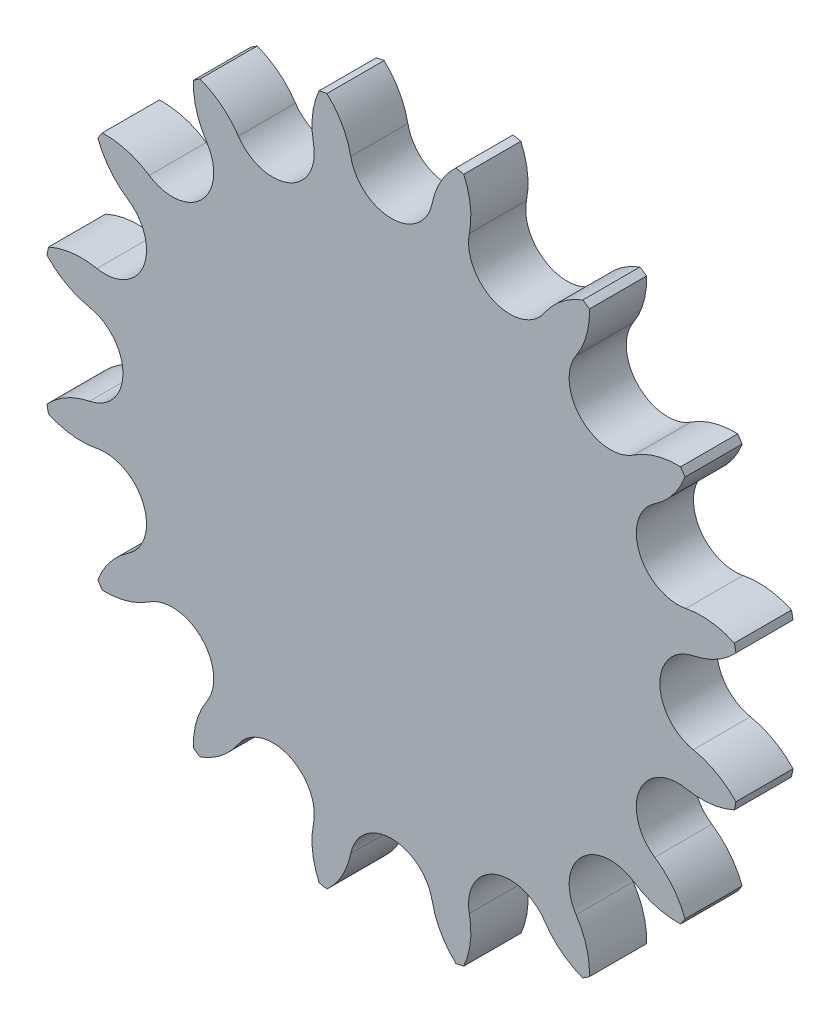
from build123d import *

# Parameters (mm, degrees)
EXTRUDE_1_DEPTH          = 6
PATTERN_CIRCULAR_1_COUNT = 16


with BuildPart() as part:
    # Эскиз2 → Бобышка-Вытянуть1 (new body)
    with BuildSketch(Plane.XY):
        with BuildLine():
            Line((0, 0), (0, 28.194026186))
            ThreePointArc((0, 28.194026186), (2.762782753, 29.182565662), (4.271319896, 31.699407834))
            ThreePointArc((4.271319896, 31.699407834), (5.166850576, 34.134348257), (6.766906166, 36.176585307))
            ThreePointArc((6.766906166, 36.176585307), (7.18010932, 36.096847143), (7.592373731, 36.012389599))
            ThreePointArc((7.592373731, 36.012389599), (8.289102058, 33.513293823), (8.184653165, 30.920997449))
            ThreePointArc((8.184653165, 30.920997449), (8.615205955, 28.018446308), (10.789386713, 26.047883733))
            Line((10.789386713, 26.047883733), (0, 0))
        make_face()
    extrude_1 = extrude(amount=EXTRUDE_1_DEPTH)

    # Круговой массив1: Бобышка-Вытянуть1 ×16 about axis
    pattern_circular_1_axis = Axis((0, 0, 0), (0, 0, 1))
    for i in range(1, PATTERN_CIRCULAR_1_COUNT):
        add(extrude_1.rotate(pattern_circular_1_axis, i * 360 / PATTERN_CIRCULAR_1_COUNT))


solid = part.part
